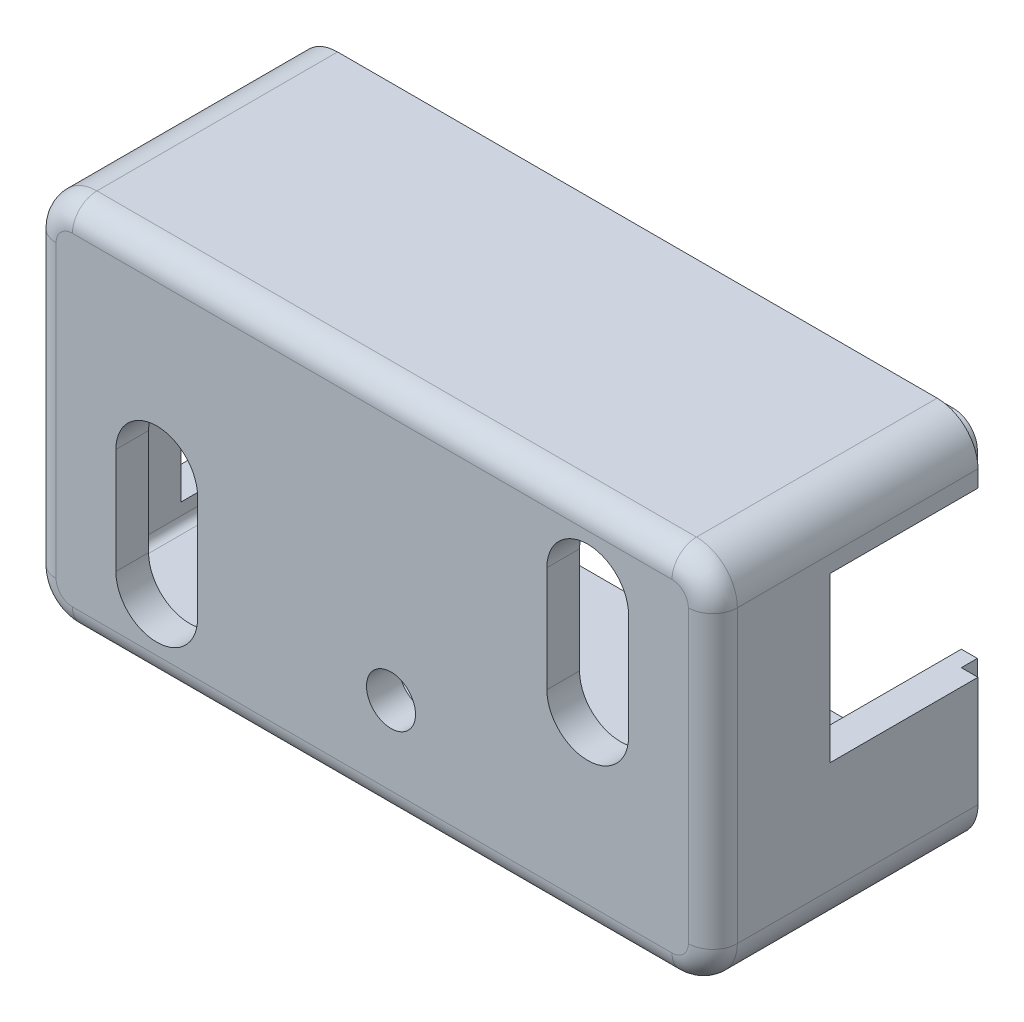
from build123d import *

# Parameters (mm, degrees)
SKETCH1_W                = 41.700000763
SKETCH1_H                = 22.799999237
BOSS_EXTRUDE1_DEPTH      = 16
BOSS_EXTRUDE1_DEPTH_BACK = 6
FILLET1_R                = 2.5
SHELL1_T                 = 2
FILLET2_R                = 1.5
SPLIT2_SURFACE_1_BACK    = 53.371
SPLIT2_SURFACE_1_DEPTH   = 106.742
SPLIT2_SURFACE_2_BACK    = 53.371
SPLIT2_SURFACE_2_DEPTH   = 106.742
SKETCH6_W                = 51.834983027
SKETCH6_H                = 10.188595942
CUT_EXTRUDE1_DEPTH       = 25
BOSS_EXTRUDE2_DEPTH      = 0.98
CUT_EXTRUDE2_DEPTH       = 11
SKETCH9_W                = 11.335588894
SKETCH9_H                = 10.028184506
CUT_EXTRUDE3_DEPTH       = 11
SKETCH10_W               = 11.009113092
SKETCH10_H               = 10.096148938
CUT_EXTRUDE4_DEPTH       = 11
SKETCH11_R               = 1.5
CUT_EXTRUDE5_DEPTH       = 11


with BuildPart() as part:
    # Sketch1 → Boss-Extrude1 (new, two sides)
    with BuildSketch(Plane.XY) as boss_extrude1_sk:
        with Locations((-17.850000382, 8.399999619)):
            Rectangle(SKETCH1_W, SKETCH1_H)
    extrude(amount=BOSS_EXTRUDE1_DEPTH)
    extrude(boss_extrude1_sk.sketch, amount=-BOSS_EXTRUDE1_DEPTH_BACK)

    # Fillet1
    fillet1_edges = [part.edges().sort_by_distance(p)[0] for p in [
        (3, -3, 5),
        (3, 19.799999237, 5),
        (-38.700000763, 19.799999237, 5),
        (-38.700000763, -3, 5),
    ]]
    fillet(fillet1_edges, radius=FILLET1_R)

    # Shell1 (no face opened: a closed hollow body)
    add(offset(amount=-SHELL1_T, mode=Mode.PRIVATE), mode=Mode.SUBTRACT)

    # Fillet2
    fillet2_edges = [part.edges().sort_by_distance(p)[0] for p in [
        (-17.850000381, -3, 16),
        (3, 8.399999619, 16),
        (-17.850000381, 19.799999237, 16),
        (-38.700000763, 8.399999619, 16),
        (-37.967767716, -2.267766953, 16),
        (-37.967767716, 19.06776619, 16),
        (2.267766953, 19.06776619, 16),
        (2.267766953, -2.267766953, 16),
    ]]
    fillet(fillet2_edges, radius=FILLET2_R)


with BuildPart() as body_2:
    # Split2: the piece behind the surface
    add(part.part)
    # Split2 surface: a surface, the sketch's curves swept straight by 106.742 mm
    with BuildLine(Plane(origin=(0, 0, 0), x_dir=(1, 0, 0), z_dir=(0, 1, 0)).offset(-SPLIT2_SURFACE_1_BACK), mode=Mode.PRIVATE) as split2_surface_1_path:
        Line((11.527694016, 0.23), (-46.74820982, 0.23))
    split2_surface_1 = Shell.extrude(split2_surface_1_path.wire(), (0 * SPLIT2_SURFACE_1_DEPTH, 1 * SPLIT2_SURFACE_1_DEPTH, 0 * SPLIT2_SURFACE_1_DEPTH))
    split(bisect_by=split2_surface_1, keep=Keep.BOTTOM)

    # Sketch6 → Cut-Extrude1 (cut)
    with BuildSketch(Plane.XZ.offset(3)):
        with Locations((-19.404183034, -5.324297971)):
            Rectangle(SKETCH6_W, SKETCH6_H)
    extrude(amount=-CUT_EXTRUDE1_DEPTH, mode=Mode.SUBTRACT)


with BuildPart() as part_1:
    add(part.part)

    # Split2: split by a surface, the side it looks to stays
    # Split2 surface: a surface, the sketch's curves swept straight by 106.742 mm
    with BuildLine(Plane(origin=(0, 0, 0), x_dir=(1, 0, 0), z_dir=(0, 1, 0)).offset(-SPLIT2_SURFACE_2_BACK), mode=Mode.PRIVATE) as split2_surface_2_path:
        Line((11.527694016, 0.23), (-46.74820982, 0.23))
    split2_surface_2 = Shell.extrude(split2_surface_2_path.wire(), (0 * SPLIT2_SURFACE_2_DEPTH, 1 * SPLIT2_SURFACE_2_DEPTH, 0 * SPLIT2_SURFACE_2_DEPTH))
    split(bisect_by=split2_surface_2, keep=Keep.TOP)

    # Sketch7 → Boss-Extrude2 (add)
    with BuildSketch(Plane(origin=(0, 0, -0.23), x_dir=(-1, 0, 0), z_dir=(0, 0, -1))):
        with BuildLine():
            Line((-0.5, -1.98), (36.200000763, -1.98))
            ThreePointArc((36.200000763, -1.98), (37.246518799, -1.546518036), (37.680000763, -0.5))
            Line((37.680000763, -0.5), (37.680000763, 17.299999237))
            ThreePointArc((37.680000763, 17.299999237), (37.246518799, 18.346517273), (36.200000763, 18.779999237))
            Line((36.200000763, 18.779999237), (-0.5, 18.779999237))
            ThreePointArc((-0.5, 18.779999237), (-1.546518036, 18.346517273), (-1.98, 17.299999237))
            Line((-1.98, 17.299999237), (-1.98, -0.5))
            ThreePointArc((-1.98, -0.5), (-1.546518036, -1.546518036), (-0.5, -1.98))
        make_face()
        with BuildLine():
            Line((-0.5, -1), (36.200000763, -1))
            ThreePointArc((36.200000763, -1), (36.553554154, -0.853553391), (36.700000763, -0.5))
            Line((36.700000763, -0.5), (36.700000763, 17.299999237))
            ThreePointArc((36.700000763, 17.299999237), (36.553554154, 17.653552628), (36.200000763, 17.799999237))
            Line((36.200000763, 17.799999237), (-0.5, 17.799999237))
            ThreePointArc((-0.5, 17.799999237), (-0.853553391, 17.653552628), (-1, 17.299999237))
            Line((-1, 17.299999237), (-1, -0.5))
            ThreePointArc((-1, -0.5), (-0.853553391, -0.853553391), (-0.5, -1))
        make_face(mode=Mode.SUBTRACT)
    extrude(amount=BOSS_EXTRUDE2_DEPTH)

    # Sketch8 → Cut-Extrude2 (cut)
    with BuildSketch(Plane.XY.offset(16)):
        with BuildLine():
            Line((-2.16, 15.093417893), (-2.16, 8.627866409))
            ThreePointArc((-2.16, 8.627866409), (-4.66, 6.127866409), (-7.16, 8.627866409))
            Line((-7.16, 8.627866409), (-7.16, 15.093417893))
            ThreePointArc((-7.16, 15.093417893), (-4.66, 17.593417893), (-2.16, 15.093417893))
        make_face()
        with BuildLine():
            Line((-33.540000763, 1.706581344), (-33.540000763, 8.172132828))
            ThreePointArc((-33.540000763, 8.172132828), (-31.040000763, 10.672132828), (-28.540000763, 8.172132828))
            Line((-28.540000763, 8.172132828), (-28.540000763, 1.706581344))
            ThreePointArc((-28.540000763, 1.706581344), (-31.040000763, -0.793418656), (-33.540000763, 1.706581344))
        make_face()
    extrude(amount=-CUT_EXTRUDE2_DEPTH, mode=Mode.SUBTRACT)

    # Sketch9 → Cut-Extrude3 (cut)
    with BuildSketch(Plane(origin=(3, 0, 0), x_dir=(0, 0, -1), z_dir=(1, 0, 0))):
        with Locations((-3.175571545, 11.266589504)):
            Rectangle(SKETCH9_W, SKETCH9_H)
    extrude(amount=-CUT_EXTRUDE3_DEPTH, mode=Mode.SUBTRACT)

    # Sketch10 → Cut-Extrude4 (cut)
    with BuildSketch(Plane.ZY.offset(38.700000763)):
        with Locations((3.338809446, 5.283196064)):
            Rectangle(SKETCH10_W, SKETCH10_H)
    extrude(amount=-CUT_EXTRUDE4_DEPTH, mode=Mode.SUBTRACT)

    # Sketch11 → Cut-Extrude5 (cut)
    with BuildSketch(Plane.XY.offset(16)):
        with Locations((-16.7, 3.3)):
            Circle(SKETCH11_R)
    extrude(amount=-CUT_EXTRUDE5_DEPTH, mode=Mode.SUBTRACT)


solid = part_1.part
